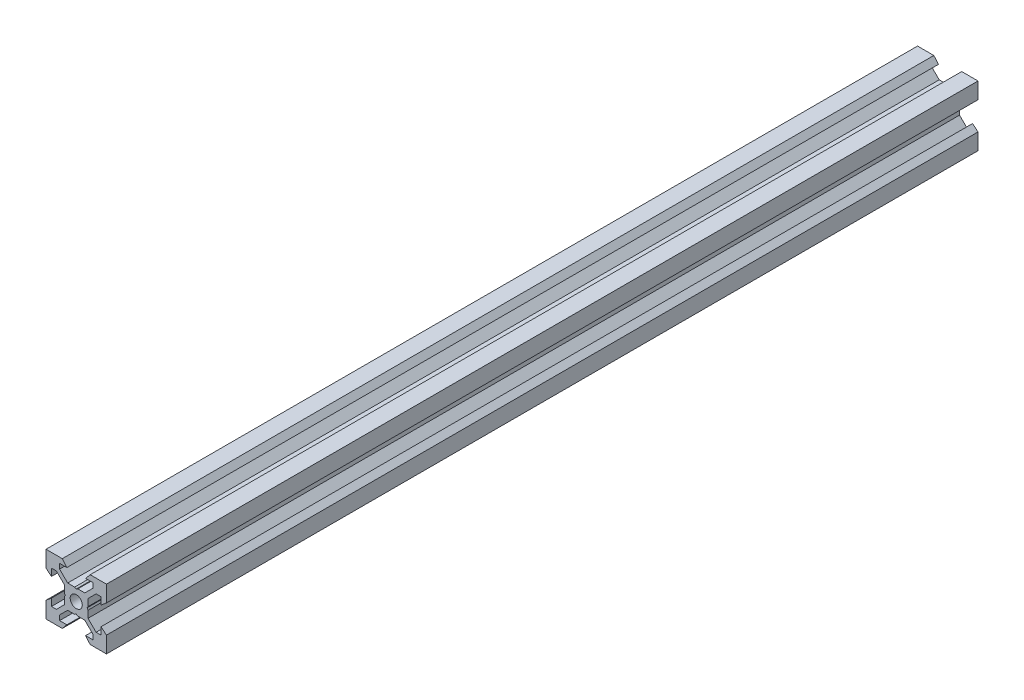
from build123d import *

# Parameters (mm, degrees)
SKETCH1_R           = 2
BOSS_EXTRUDE1_DEPTH = 144.165


with BuildPart() as part:
    # Sketch1 → Boss-Extrude1 (new body, symmetric)
    with BuildSketch(Plane.XY):
        Polygon((10, 10), (10, 4.610379336), (8.2, 3.1), (8.2, 5.5), (6.560660172, 5.5), (3.9, 2.839339828), (3.9, 0.519615242), (3.6, 0), (3.9, -0.519615242), (3.9, -2.839339828), (6.560660172, -5.5), (8.2, -5.5), (8.2, -3.1), (10, -4.610379336), (10, -10), (4.610379336, -10), (3.1, -8.2), (5.5, -8.2), (5.5, -6.560660172), (2.839339828, -3.9), (0.519615242, -3.9), (0, -3.6), (-0.519615242, -3.9), (-2.839339828, -3.9), (-5.5, -6.560660172), (-5.5, -8.2), (-3.1, -8.2), (-4.610379336, -10), (-10, -10), (-10, -4.610379336), (-8.2, -3.1), (-8.2, -5.5), (-6.560660172, -5.5), (-3.9, -2.839339828), (-3.9, -0.519615242), (-3.6, 0), (-3.9, 0.519615242), (-3.9, 2.839339828), (-6.560660172, 5.5), (-8.2, 5.5), (-8.2, 3.1), (-10, 4.610379336), (-10, 10), (-4.610379336, 10), (-3.1, 8.2), (-5.5, 8.2), (-5.5, 6.560660172), (-2.839339828, 3.9), (-0.519615242, 3.9), (0, 3.6), (0.519615242, 3.9), (2.839339828, 3.9), (5.5, 6.560660172), (5.5, 8.2), (3.1, 8.2), (4.610379336, 10), align=None)
        Circle(SKETCH1_R, mode=Mode.SUBTRACT)
    extrude(amount=BOSS_EXTRUDE1_DEPTH, both=True)


solid = part.part
